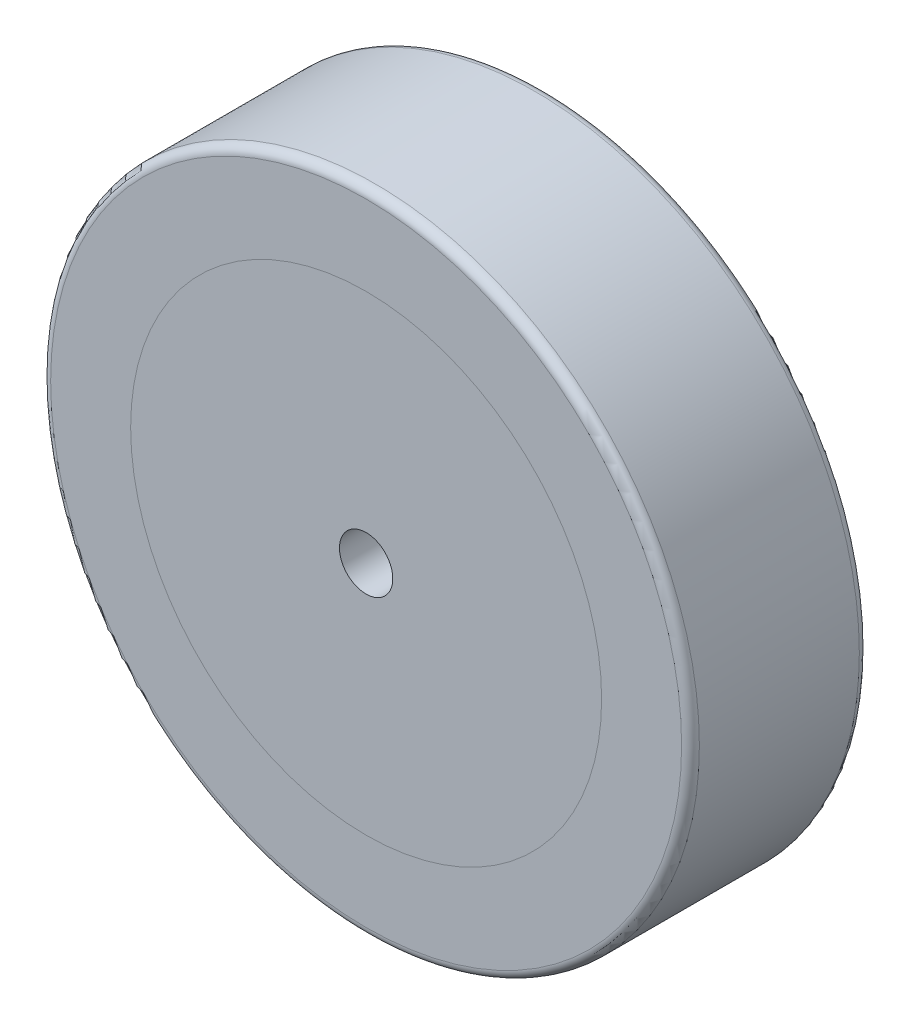
from build123d import *

# Parameters (mm, degrees)
ESQUISSE1_R             = 36.5
BOSS_EXTRU_1_DEPTH      = 20
ESQUISSE2_R             = 26.5
ENL_V_MAT_EXTRU_2_DEPTH = 20
ESQUISSE4_R             = 26.5
BOSS_EXTRU_3_DEPTH      = 20
ESQUISSE9_W             = 3
ESQUISSE9_H             = 20
CONG_1_R                = 1


with BuildPart() as part:
    # Esquisse1 → Boss.-Extru.1 (new body)
    with BuildSketch(Plane.XY):
        Circle(ESQUISSE1_R)
    extrude(amount=BOSS_EXTRU_1_DEPTH)

    # Esquisse2 → Enlèv. mat.-Extru.2 (cut)
    with BuildSketch(Plane.XY.offset(20)):
        Circle(ESQUISSE2_R)
    extrude(amount=-ENL_V_MAT_EXTRU_2_DEPTH, mode=Mode.SUBTRACT)

    # Congé1
    cong_1_edges = [part.edges().sort_by_distance(p)[0] for p in [
        (-36.5, 0, 0),
        (-36.5, 0, 20),
    ]]
    fillet(cong_1_edges, radius=CONG_1_R)


with BuildPart() as body_2:
    # Esquisse4 → Boss.-Extru.3 (new body)
    with BuildSketch(Plane.XY.offset(20)):
        Circle(ESQUISSE4_R)
    extrude(amount=-BOSS_EXTRU_3_DEPTH)

    # Esquisse9 → Dégagement M81 (revolve, cut)
    with BuildSketch(Plane.YZ):
        with Locations((1.5, 10)):
            Rectangle(ESQUISSE9_W, ESQUISSE9_H)
    revolve(axis=Axis((0, 0, -6.35), (0, 0, 1)), mode=Mode.SUBTRACT)


solid = Compound([part.part, body_2.part])
